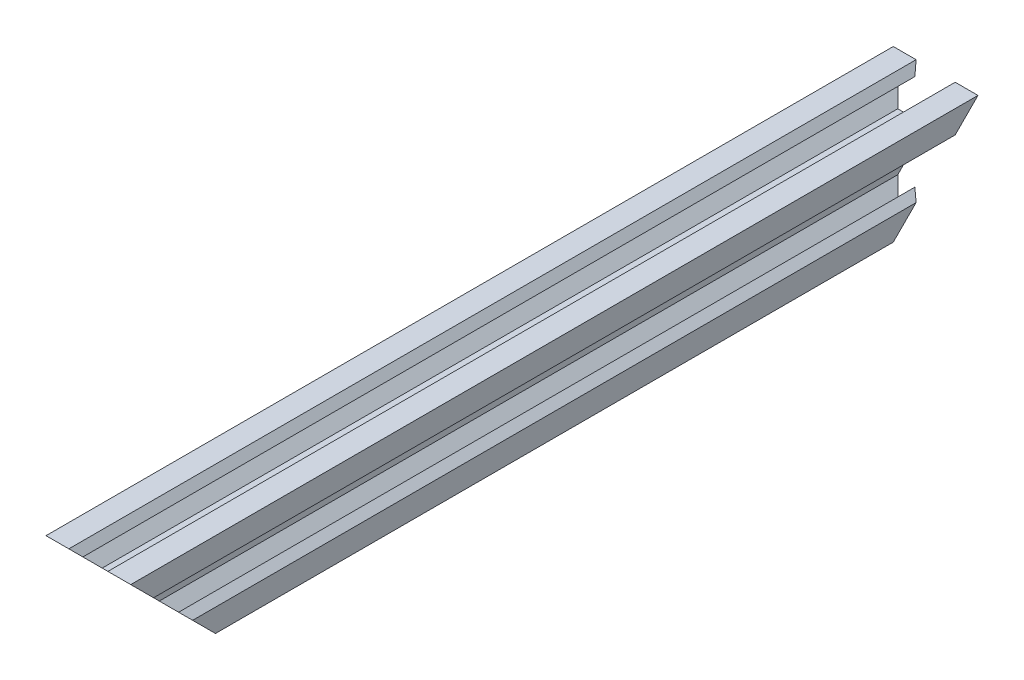
from build123d import *

# Parameters (mm, degrees)
SKETCH1_R           = 2
BOSS_EXTRUDE1_DEPTH = 100
CUT_EXTRUDE1_REACH  = 22


with BuildPart() as part:
    # Sketch1 → Boss-Extrude1 (new body, symmetric)
    with BuildSketch(Plane.XY):
        Polygon((10, 10), (10, 4.610379336), (8.2, 3.1), (8.2, 5.5), (6.560660172, 5.5), (3.9, 2.839339828), (3.9, 0.519615242), (3.6, 0), (3.9, -0.519615242), (3.9, -2.839339828), (6.560660172, -5.5), (8.2, -5.5), (8.2, -3.1), (10, -4.610379336), (10, -10), (4.610379336, -10), (3.1, -8.2), (5.5, -8.2), (5.5, -6.560660172), (2.839339828, -3.9), (0.519615242, -3.9), (0, -3.6), (-0.519615242, -3.9), (-2.839339828, -3.9), (-5.5, -6.560660172), (-5.5, -8.2), (-3.1, -8.2), (-4.610379336, -10), (-10, -10), (-10, -4.610379336), (-8.2, -3.1), (-8.2, -5.5), (-6.560660172, -5.5), (-3.9, -2.839339828), (-3.9, -0.519615242), (-3.6, 0), (-3.9, 0.519615242), (-3.9, 2.839339828), (-6.560660172, 5.5), (-8.2, 5.5), (-8.2, 3.1), (-10, 4.610379336), (-10, 10), (-4.610379336, 10), (-3.1, 8.2), (-5.5, 8.2), (-5.5, 6.560660172), (-2.839339828, 3.9), (-0.519615242, 3.9), (0, 3.6), (0.519615242, 3.9), (2.839339828, 3.9), (5.5, 6.560660172), (5.5, 8.2), (3.1, 8.2), (4.610379336, 10), align=None)
        Circle(SKETCH1_R, mode=Mode.SUBTRACT)
    extrude(amount=BOSS_EXTRUDE1_DEPTH, both=True)

    # Sketch2 → Cut-Extrude1 (cut, up to next)
    with BuildSketch(Plane(origin=(10, 0, 0), x_dir=(0, 0, -1), z_dir=(1, 0, 0)), mode=Mode.PRIVATE) as cut_extrude1_sk1:
        Polygon((100, 10), (80, -10), (100, -10), align=None)
    cut_extrude1_tool1 = extrude(cut_extrude1_sk1.sketch, amount=-CUT_EXTRUDE1_REACH, mode=Mode.PRIVATE) & part.part
    add(cut_extrude1_tool1.solids().sort_by_distance((10, -3.333333, -93.333333))[0], mode=Mode.SUBTRACT)
    # Sketch2 → Cut-Extrude1 (cut, up to next)
    with BuildSketch(Plane(origin=(10, 0, 0), x_dir=(0, 0, -1), z_dir=(1, 0, 0)), mode=Mode.PRIVATE) as cut_extrude1_sk2:
        Polygon((-100, 10), (-80, -10), (-100, -10), align=None)
    cut_extrude1_tool2 = extrude(cut_extrude1_sk2.sketch, amount=-CUT_EXTRUDE1_REACH, mode=Mode.PRIVATE) & part.part
    add(cut_extrude1_tool2.solids().sort_by_distance((10, -3.333333, 93.333333))[0], mode=Mode.SUBTRACT)


solid = part.part
